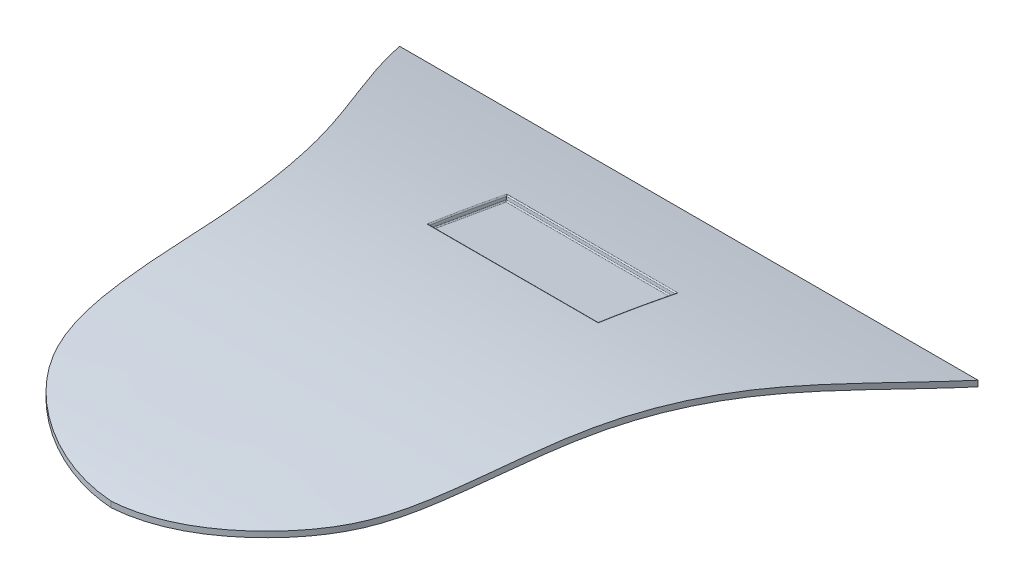
from build123d import *

# Parameters (mm, degrees)
EXTRUSION1_DEPTH = 10
EXTRUSION2_DEPTH = 30
ESQUISSE4_W      = 17
ESQUISSE4_H      = 8
EXTRUSION3_DEPTH = 0.8
ESQUISSE5_W      = 15
ESQUISSE5_H      = 7
EXTRUSION7_DEPTH = 0.7
CONG_2_R         = 0.1
CONG_5_R         = 0.1


with BuildPart() as part:
    # Esquisse1 → Extrusion1 (new body)
    with BuildSketch(Plane(origin=(0, 0, 0), x_dir=(1, 0, 0), z_dir=(0, 1, 0))):
        with BuildLine():
            Line((-25.641316101, -201), (25.641316101, -201))
            add(Edge.make_bspline(
                [(25.641316101, -201), (23.961049197, -205.278468332), (19.305708091, -212.773074895), (16.083009164, -224.954729791), (15.713379911, -235.241152719), (14.080356119, -243.738213975), (9.462029064, -248.891319158), (4.565170001, -251.505395445), (1.381112368, -252.133900376), (0, -252.2146295)],
                knots=[0, 0, 0, 0, 0.223170088, 0.426641356, 0.602759267, 0.727118956, 0.836394536, 0.926386241, 0.993099763, 0.993099763, 0.993099763, 0.993099763], degree=3))
            add(Edge.make_bspline(
                [(-25.641316101, -201), (-23.961049197, -205.278468332), (-19.305708091, -212.773074895), (-16.083009164, -224.954729791), (-15.713379911, -235.241152719), (-14.080356119, -243.738213975), (-9.462029064, -248.891319158), (-4.565170001, -251.505395445), (-1.381112368, -252.133900376), (0, -252.2146295)],
                knots=[0, 0, 0, 0, 0.223170088, 0.426641356, 0.602759267, 0.727118956, 0.836394536, 0.926386241, 0.993099763, 0.993099763, 0.993099763, 0.993099763], degree=3))
        make_face()
    extrude(amount=EXTRUSION1_DEPTH)

    # Esquisse2 → Extrusion2 (cut, symmetric)
    with BuildSketch(Plane(origin=(0, 0, 0), x_dir=(0, 0, -1), z_dir=(1, 0, 0))):
        with BuildLine():
            Line((-252.787493368, 6.043954287), (-253.171138035, 11.305561743))
            Line((-253.171138035, 11.305561743), (-199.882908702, 11.305561743))
            Line((-199.882908702, 11.305561743), (-200.879712513, 2.641701079))
            add(Edge.make_bspline(
                [(-200.879712513, 2.641701079), (-205.10674209, 3.689388604), (-211.483407763, 5.116909862), (-220.121635134, 6.382308922), (-226.644990054, 6.934944246), (-233.181400008, 7.166324552), (-238.630143526, 7.119206442), (-242.975440676, 6.968750009), (-246.236108109, 6.857455978), (-249.510950449, 6.637644262), (-251.709528624, 6.290716102), (-252.787493368, 6.043954287)],
                knots=[0, 0, 0, 0, 0.25, 0.375, 0.5, 0.625, 0.75, 0.8125, 0.875, 0.9375, 1, 1, 1, 1], degree=3))
        make_face()
        with BuildLine():
            Line((-252.675922041, 5.556561387), (-252.675922041, -1.489505522))
            Line((-252.675922041, -1.489505522), (-199.255606978, -1.489505522))
            Line((-199.255606978, -1.489505522), (-201, 2.1563858))
            add(Edge.make_bspline(
                [(-201, 2.1563858), (-206.984873082, 3.639762424), (-216.188281532, 5.605286421), (-228.640990072, 6.593485274), (-236.933253428, 6.683235069), (-244.91998294, 6.402233319), (-249.817185498, 6.210967779), (-252.675922041, 5.556561387)],
                knots=[0, 0, 0, 0, 0.355292645, 0.539868556, 0.718237101, 0.83233796, 1, 1, 1, 1], degree=3))
        make_face()
    extrude(amount=EXTRUSION2_DEPTH, both=True, mode=Mode.SUBTRACT)

    # Esquisse4 → Extrusion3 (add)
    with BuildSketch(Plane(origin=(0, -31.47515502, 5.549919052), x_dir=(1, 0, 0), z_dir=(0, -0.984807753, 0.173648178))):
        with Locations((0, 210.748859145)):
            Rectangle(ESQUISSE4_W, ESQUISSE4_H)
    extrude(amount=EXTRUSION3_DEPTH)

    # Esquisse5 → Extrusion7 (cut)
    with BuildSketch(Plane(origin=(0, -31.09341759, 5.482608444), x_dir=(1, 0, 0), z_dir=(0, -0.984807753, 0.173648178))):
        with Locations((0, 210.748859145)):
            Rectangle(ESQUISSE5_W, ESQUISSE5_H)
    extrude(amount=EXTRUSION7_DEPTH, mode=Mode.SUBTRACT)

    # Congé2
    cong_2_edges = [part.edges().sort_by_distance(p)[0] for p in [
        (-3.7499994, 4.626738534, 209.630188022),
        (-7.5, 5.278128057, 213.069352394),
        (-3.7499994, 5.840034496, 216.524237492),
        (7.5, 5.278128057, 213.069352394),
        (7.5, 4.813372319, 213.151272592),
        (0, 5.421140941, 216.598099728),
        (-7.5, 4.813372319, 213.151272592),
        (0, 4.205603697, 209.704445456),
    ]]
    fillet(cong_2_edges, radius=CONG_2_R)

    # Congé5
    cong_5_edges = [part.edges().sort_by_distance(p)[0] for p in [
        (-4.25, 5.420362494, 217.105950295),
        (8.5, 4.785598732, 213.156216965),
        (-4.25, 4.03401425, 209.226988),
        (-8.5, 4.785598732, 213.156216965),
        (-8.5, 5.224054659, 217.140564662),
        (-8.5, 3.836287826, 209.261852503),
        (8.5, 3.836287826, 209.261852503),
        (8.5, 5.224054659, 217.140564662),
        (0, 3.638561403, 209.296717006),
        (8.5, 4.333154113, 213.235948018),
        (0, 5.027746824, 217.17517903),
    ]]
    fillet(cong_5_edges, radius=CONG_5_R)


solid = part.part
